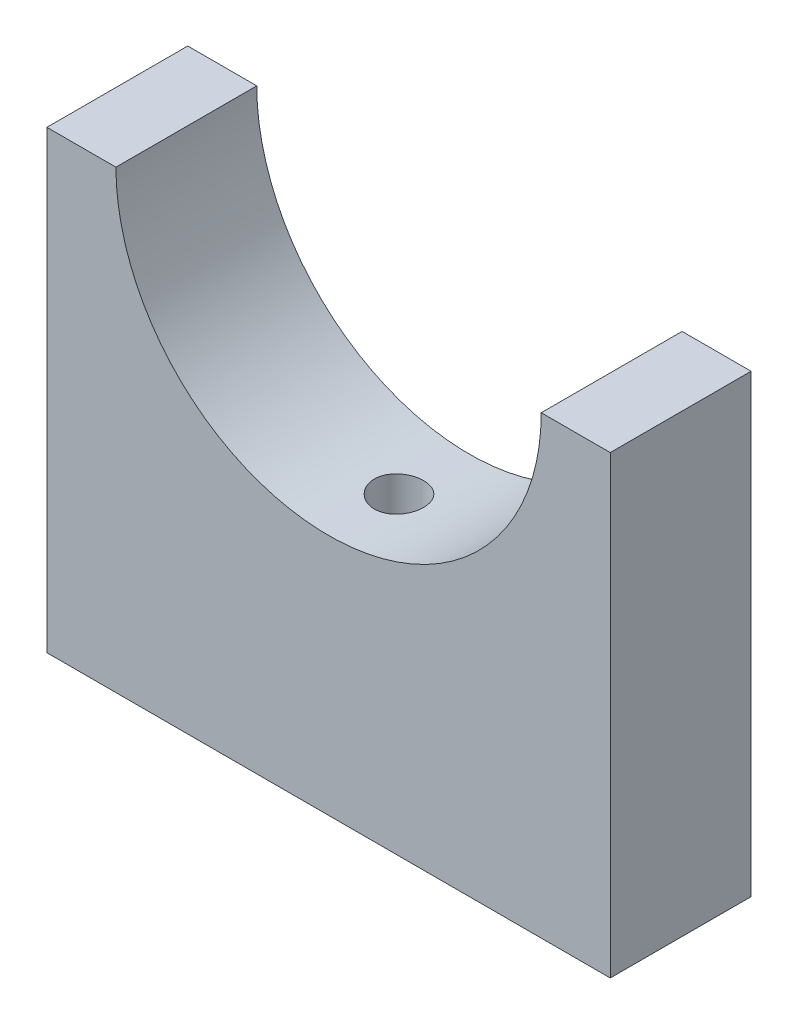
from build123d import *

# Parameters (mm, degrees)
SKETCH1_W            = 80
SKETCH1_H            = 64.62
BOSS_EXTRUDE1_DEPTH  = 10
CUT_EXTRUDE1_DEPTH   = 20
M6_CLEARANCE_HOLE1_D = 7


with BuildPart() as part:
    # Sketch1 → Boss-Extrude1 (new body, symmetric)
    with BuildSketch(Plane.XY):
        Rectangle(SKETCH1_W, SKETCH1_H)
    extrude(amount=BOSS_EXTRUDE1_DEPTH, both=True)

    # Sketch2 → Cut-Extrude1 (cut)
    with BuildSketch(Plane.XY.offset(10)):
        with BuildLine():
            Line((-30.2, 32.31), (30.2, 32.31))
            ThreePointArc((30.2, 32.31), (0, 2.11), (-30.2, 32.31))
        make_face()
    extrude(amount=-CUT_EXTRUDE1_DEPTH, mode=Mode.SUBTRACT)

    # M6 Clearance Hole1 (through all)
    with Locations(Plane(origin=(0, -32.31, 0), x_dir=(-1, 0, 0), z_dir=(0, -1, 0))):
        with Locations((0, 0)):
            Hole(M6_CLEARANCE_HOLE1_D / 2)


solid = part.part
